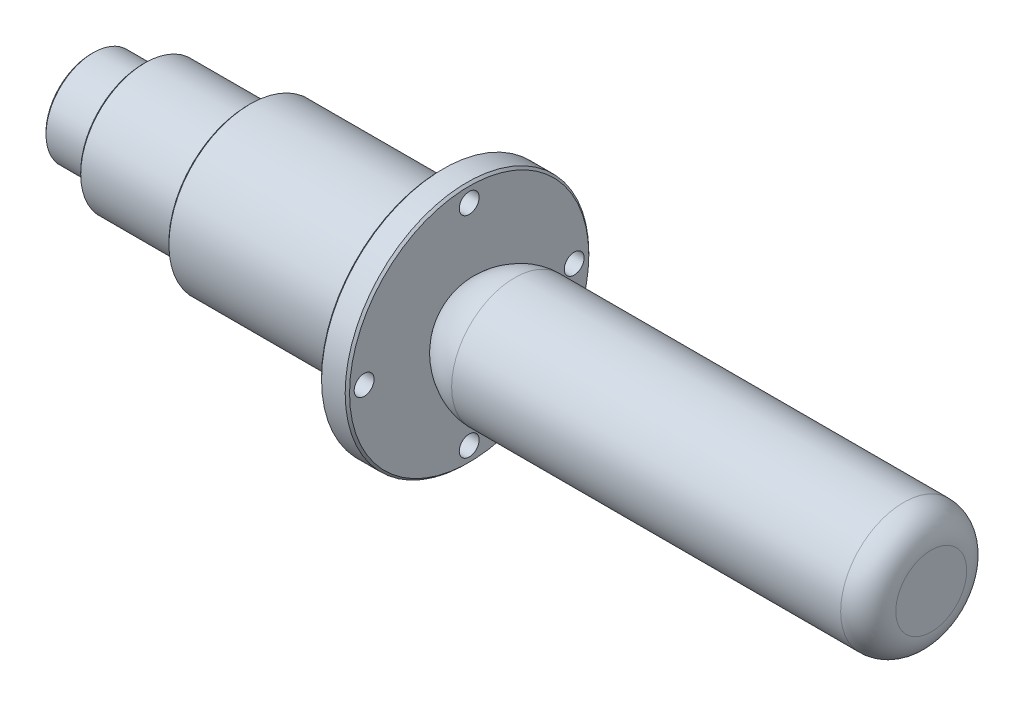
from build123d import *

# Parameters (mm, degrees)
SKETCH2_R          = 1.8034
CUT_EXTRUDE1_DEPTH = 5.08
CIRPATTERN2_COUNT  = 4
CHAMFER1_SIZE      = 0.396875


with BuildPart() as part:
    # Sketch1 → Revolve1 (revolve)
    with BuildSketch(Plane.XY):
        with BuildLine():
            Line((-19.670349573, 0), (-19.670349573, 8.580640426))
            Line((-19.670349573, 8.580640426), (-10.272349573, 8.580640426))
            Line((-10.272349573, 8.580640426), (-10.272349573, 11.684))
            Line((-10.272349573, 11.684), (8.777650427, 11.684))
            Line((8.777650427, 11.684), (8.777650427, 14.732))
            Line((8.777650427, 14.732), (43.829650427, 14.732))
            Line((43.829650427, 14.732), (43.829650427, 22.098))
            Line((43.829650427, 22.098), (48.909650427, 22.098))
            Line((48.909650427, 22.098), (48.909650427, 7.055193239))
            add(Edge.make_bspline(
                [(48.909650427, 7.055193239), (50.745745469, 9.469407322), (54.078310122, 11.43), (57.155980429, 11.43)],
                knots=[0, 0, 0, 0, 1, 1, 1, 1], degree=3))
            Line((57.155980429, 11.43), (127.729650427, 11.43))
            ThreePointArc((127.729650427, 11.43), (131.265184333, 9.965533906), (132.729650427, 6.43))
            Line((132.729650427, 6.43), (132.729650427, 0))
            Line((132.729650427, 0), (-19.670349573, 0))
        make_face()
    revolve(axis=Axis((-19.670349573, 0, 0), (1, 0, 0)))

    # Sketch2 → Cut-Extrude1 (cut)
    with BuildSketch(Plane(origin=(48.909650427, 0, 0), x_dir=(0, 0, -1), z_dir=(1, 0, 0))):
        with Locations((0, 19.05)):
            Circle(SKETCH2_R)
    cut_extrude1 = extrude(amount=-CUT_EXTRUDE1_DEPTH, mode=Mode.SUBTRACT)

    # CirPattern2: Cut-Extrude1 ×4 about axis
    cirpattern2_axis = Axis((0, 0, 0), (1, 0, 0))
    for i in range(1, CIRPATTERN2_COUNT):
        add(cut_extrude1.rotate(cirpattern2_axis, i * 360 / CIRPATTERN2_COUNT), mode=Mode.SUBTRACT)

    # Chamfer1
    chamfer1_edges = [part.edges().sort_by_distance(p)[0] for p in [
        (48.909650427, -22.098, 0),
        (43.829650427, -22.098, 0),
        (8.777650427, -14.732, 0),
        (-10.272349573, -11.684, 0),
        (-19.670349573, -8.580640426, 0),
    ]]
    chamfer(chamfer1_edges, length=CHAMFER1_SIZE)


solid = part.part
